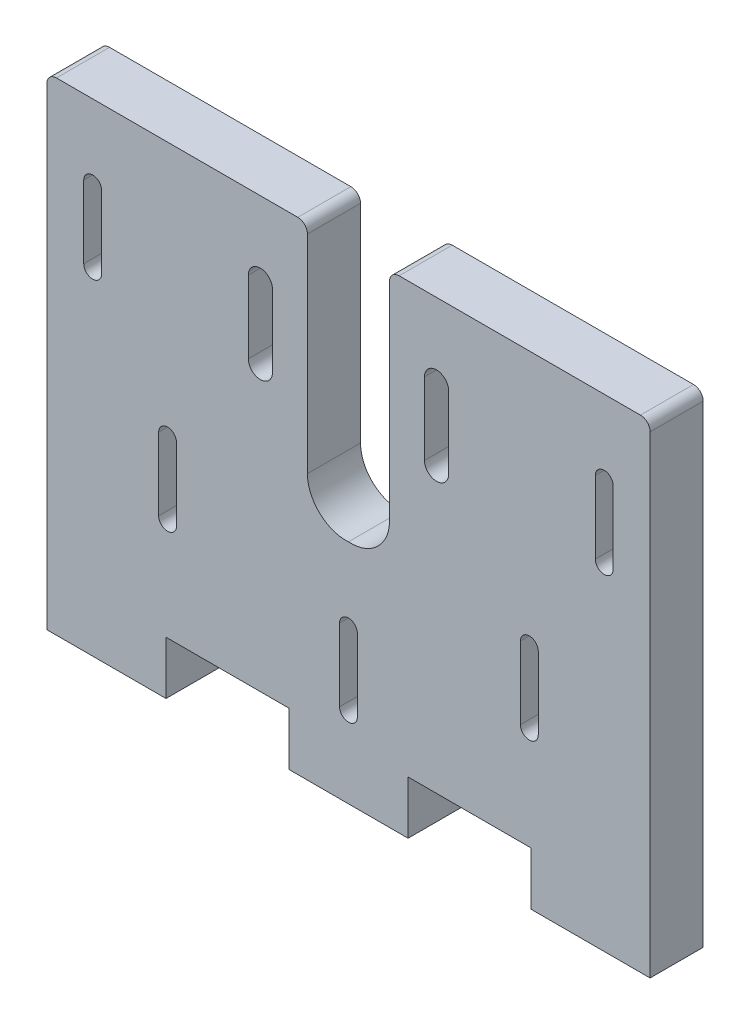
from build123d import *

# Parameters (mm, degrees)
BOSS_EXTRUDE7_DEPTH = 11


with BuildPart() as part:
    # Sketch2 → Boss-Extrude7 (new body)
    with BuildSketch(Plane.XY):
        with BuildLine():
            Line((-0.187241808, 0), (-0.187241808, 98))
            ThreePointArc((-0.187241808, 98), (0.39854463, 99.414213562), (1.812758192, 100))
            Line((1.812758192, 100), (51.812758192, 100))
            ThreePointArc((51.812758192, 100), (53.226971755, 99.414213562), (53.812758192, 98))
            Line((53.812758192, 98), (53.812758192, 55))
            ThreePointArc((53.812758192, 55), (56.335532617, 49.169048105), (62.312758192, 47.015640289))
            ThreePointArc((62.312758192, 47.015640289), (68.289983767, 49.169048105), (70.812758192, 55))
            Line((70.812758192, 55), (70.812758192, 98))
            ThreePointArc((70.812758192, 98), (71.39854463, 99.414213562), (72.812758192, 100))
            Line((72.812758192, 100), (122.812758192, 100))
            ThreePointArc((122.812758192, 100), (124.226971755, 99.414213562), (124.812758192, 98))
            Line((124.812758192, 98), (124.812758192, 0))
            Line((124.812758192, 0), (100.112758192, 0))
            Line((100.112758192, 0), (100.112758192, 11))
            Line((100.112758192, 11), (74.662758192, 11))
            Line((74.662758192, 11), (74.662758192, 0))
            Line((74.662758192, 0), (49.962758192, 0))
            Line((49.962758192, 0), (49.962758192, 11))
            Line((49.962758192, 11), (24.512758192, 11))
            Line((24.512758192, 11), (24.512758192, 0))
            Line((24.512758192, 0), (-0.187241808, 0))
        make_face()
        with BuildLine():
            Line((41.562758192, 69.5), (41.562758192, 84.5))
            ThreePointArc((41.562758192, 84.5), (44.062758192, 87), (46.562758192, 84.5))
            Line((46.562758192, 84.5), (46.562758192, 69.5))
            ThreePointArc((46.562758192, 69.5), (44.062758192, 67), (41.562758192, 69.5))
        make_face(mode=Mode.SUBTRACT)
        with BuildLine():
            Line((83.062758192, 69.5), (83.062758192, 84.5))
            ThreePointArc((83.062758192, 84.5), (80.562758192, 87), (78.062758192, 84.5))
            Line((78.062758192, 84.5), (78.062758192, 69.5))
            ThreePointArc((78.062758192, 69.5), (80.562758192, 67), (83.062758192, 69.5))
        make_face(mode=Mode.SUBTRACT)
        with BuildLine():
            Line((7.462758192, 69.5), (7.462758192, 84.5))
            ThreePointArc((7.462758192, 84.5), (9.312758192, 86.35), (11.162758192, 84.5))
            Line((11.162758192, 84.5), (11.162758192, 69.5))
            ThreePointArc((11.162758192, 69.5), (9.312758192, 67.65), (7.462758192, 69.5))
        make_face(mode=Mode.SUBTRACT)
        with BuildLine():
            Line((22.986098789, 32.023340597), (22.986098789, 47.023340597))
            ThreePointArc((22.986098789, 47.023340597), (24.836098789, 48.873340597), (26.686098789, 47.023340597))
            Line((26.686098789, 47.023340597), (26.686098789, 32.023340597))
            ThreePointArc((26.686098789, 32.023340597), (24.836098789, 30.173340597), (22.986098789, 32.023340597))
        make_face(mode=Mode.SUBTRACT)
        with BuildLine():
            Line((60.462758192, 16.5), (60.462758192, 31.5))
            ThreePointArc((60.462758192, 31.5), (62.312758192, 33.35), (64.162758192, 31.5))
            Line((64.162758192, 31.5), (64.162758192, 16.5))
            ThreePointArc((64.162758192, 16.5), (62.312758192, 14.65), (60.462758192, 16.5))
        make_face(mode=Mode.SUBTRACT)
        with BuildLine():
            Line((97.939417595, 32.023340597), (97.939417595, 47.023340597))
            ThreePointArc((97.939417595, 47.023340597), (99.789417595, 48.873340597), (101.639417595, 47.023340597))
            Line((101.639417595, 47.023340597), (101.639417595, 32.023340597))
            ThreePointArc((101.639417595, 32.023340597), (99.789417595, 30.173340597), (97.939417595, 32.023340597))
        make_face(mode=Mode.SUBTRACT)
        with BuildLine():
            Line((113.462758192, 69.5), (113.462758192, 84.5))
            ThreePointArc((113.462758192, 84.5), (115.312758192, 86.35), (117.162758192, 84.5))
            Line((117.162758192, 84.5), (117.162758192, 69.5))
            ThreePointArc((117.162758192, 69.5), (115.312758192, 67.65), (113.462758192, 69.5))
        make_face(mode=Mode.SUBTRACT)
    extrude(amount=BOSS_EXTRUDE7_DEPTH)


solid = part.part
